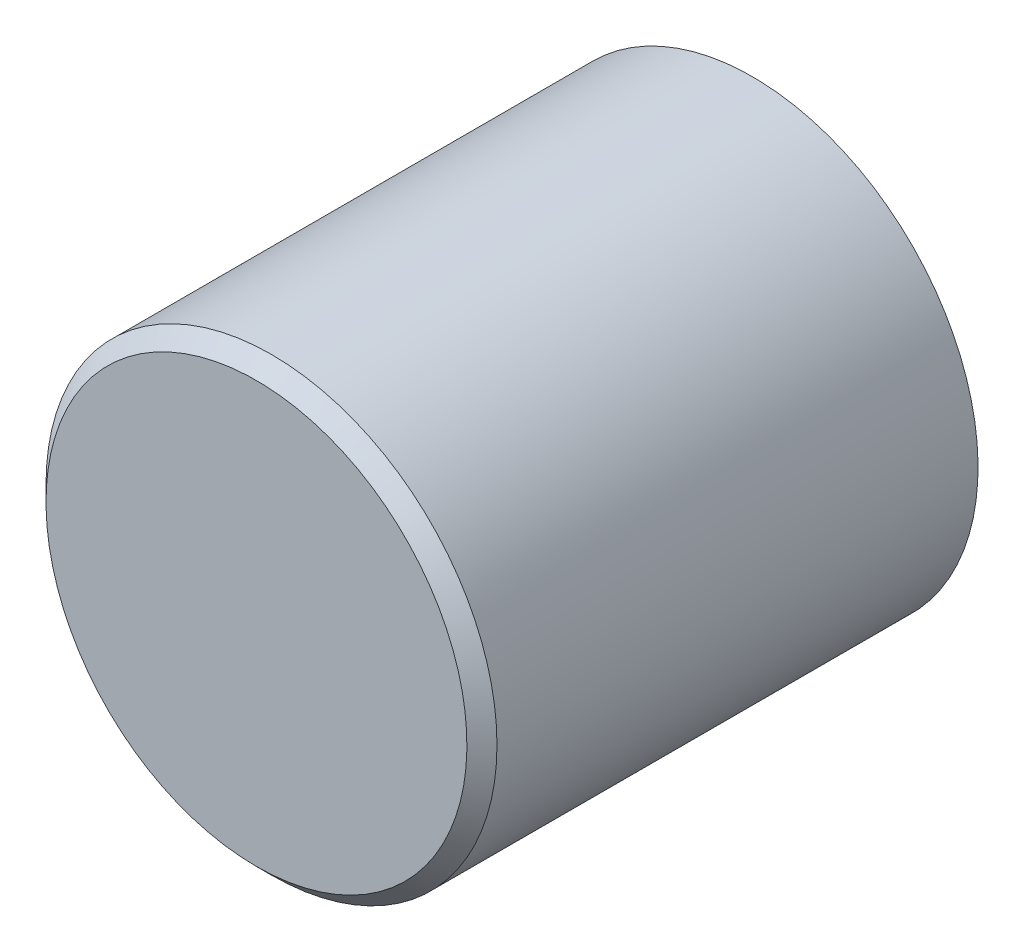
from build123d import *

# Parameters (mm, degrees)
EXTRUDE_START            = 8.875
SKETCH1_R                = 7.5
SKETCH1_R_2              = 3
EXTRUDE_KNOB_DEPTH       = 16.5
EXTRUDE_START_2          = 25.375
SKETCH1_3_R              = 3
EXTRUDE_KNOB_INNER_DEPTH = 1
CHAMFER_KNOB_SIZE        = 0.5


with BuildPart() as part:
    # Sketch1 → extrude knob (new body)
    with BuildSketch(Plane.XY.offset(EXTRUDE_START)):
        with Locations((6.776307172, 8.001648034)):
            Circle(SKETCH1_R)
        with Locations((6.776307172, 8.001648034)):
            Circle(SKETCH1_R_2, mode=Mode.SUBTRACT)
    extrude(amount=EXTRUDE_KNOB_DEPTH)

    # Sketch1_3 → extrude knob inner (add)
    with BuildSketch(Plane.XY.offset(EXTRUDE_START_2)):
        with Locations((6.776307172, 8.001648034)):
            Circle(SKETCH1_3_R)
    extrude(amount=-EXTRUDE_KNOB_INNER_DEPTH)

    # chamfer knob
    chamfer_knob_edges = [part.edges().sort_by_distance(p)[0] for p in [
        (-0.723692828, 8.001648034, 25.375),
    ]]
    chamfer(chamfer_knob_edges, length=CHAMFER_KNOB_SIZE)


solid = part.part
